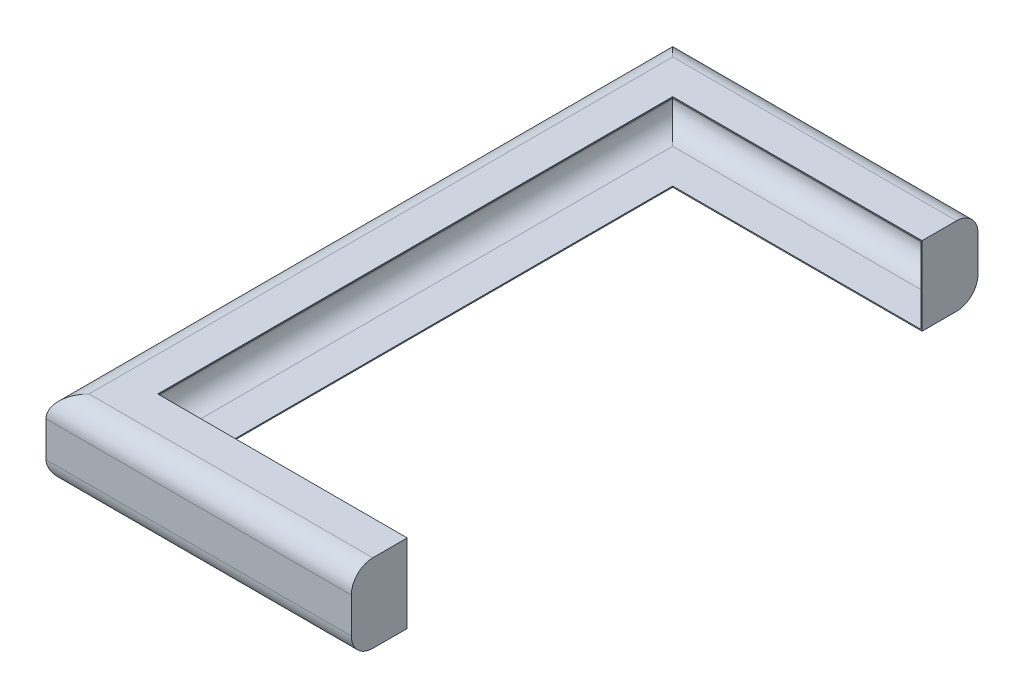
from build123d import *

# Parameters (mm, degrees)
BOSS_EXTRUDE1_DEPTH = 57.94375
FILLET1_R           = 31.75
SHELL1_T            = -1.5875


with BuildPart() as part:
    # Sketch1 → Boss-Extrude1 (new body, symmetric)
    with BuildSketch(Plane(origin=(0, 0, 0), x_dir=(1, 0, 0), z_dir=(0, 1, 0))):
        Polygon((368.3, 380.2126), (0, 380.2126), (0, -380.2126), (368.3, -380.2126), (368.3, -462.7626), (-82.55, -462.7626), (-82.55, 462.7626), (368.3, 462.7626), align=None)
    extrude(amount=BOSS_EXTRUDE1_DEPTH, both=True)

    # Fillet1
    fillet1_edges = [part.edges().sort_by_distance(p)[0] for p in [
        (142.875, -57.94375, 462.7626),
        (-82.55, -57.94375, 0),
        (142.875, -57.94375, -462.7626),
        (-82.55, 57.94375, 0),
        (142.875, 57.94375, 462.7626),
        (142.875, 57.94375, -462.7626),
    ]]
    fillet(fillet1_edges, radius=FILLET1_R)

    # Shell1
    shell1_openings = [part.faces().sort_by_distance(p)[0] for p in [
        (184.15, 0, -380.2126),
        (0, 0, 0),
        (184.15, 0, 380.2126),
    ]]
    offset(amount=SHELL1_T, openings=shell1_openings)


solid = part.part
